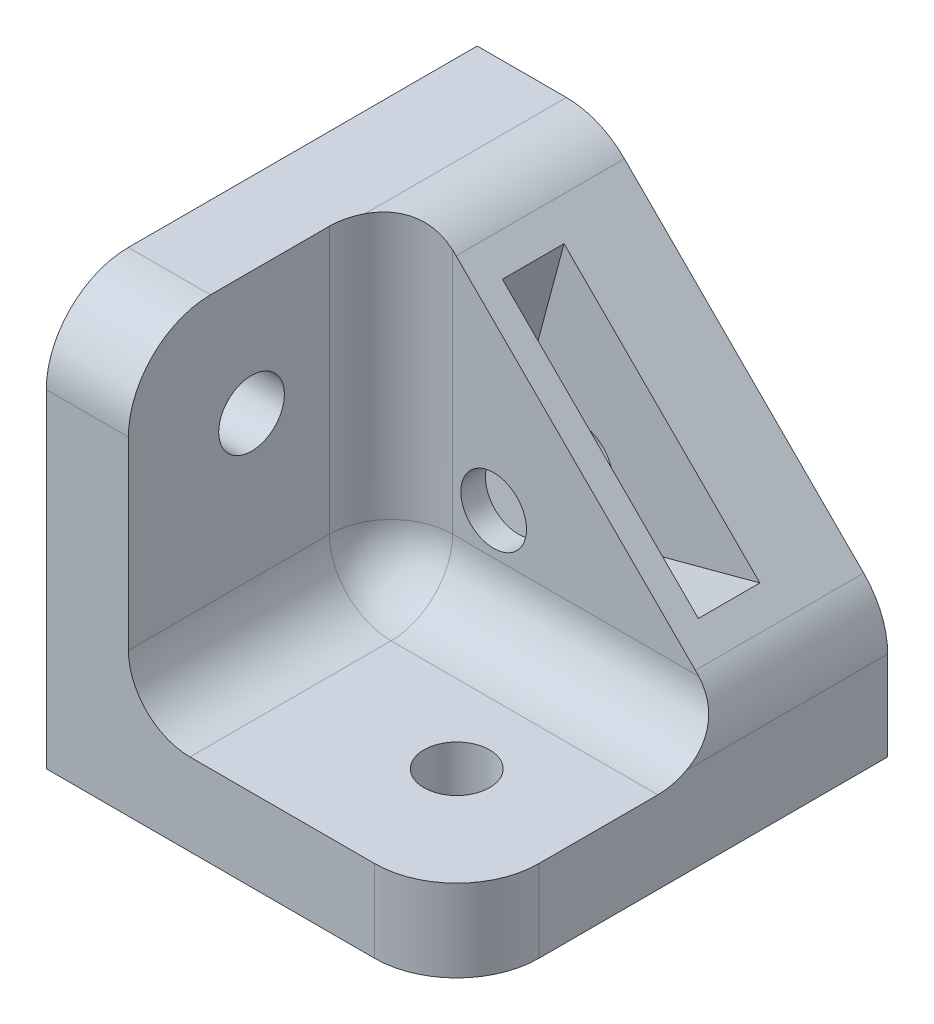
from build123d import *

# Parameters (mm, degrees)
BASE_DEPTH                           = 8.2
SIDES_DEPTH                          = 21
F_3_2_3_2_MOUNTING_HOLES_D           = 3.2
F_3_2_3_2_MOUNTING_HOLES_ON_FACE_2_D = 3.2
F_3_2_3_2_MOUNTING_HOLES_ON_FACE_3_D = 3.2
INSIDEFILLET_R                       = 3
OUTSIDEFILLET_R                      = 4
NUTSLOT_START                        = -4
NUTSLOT_DEPTH                        = 3


with BuildPart() as part:
    # Sketch4 → Base (new body)
    with BuildSketch(Plane.XY):
        Polygon((0, 20), (0, 0), (20, 0), (20, 6), (6, 20), align=None)
    extrude(amount=BASE_DEPTH)

    # Sketch4_4 → Sides (add)
    with BuildSketch(Plane.XY):
        Polygon((0, 20), (0, 0), (20, 0), (20, 4), (4, 4), (4, 20), align=None)
    extrude(amount=SIDES_DEPTH)

    # Ø3.2 (3.2) Mounting Holes (through all)
    with Locations(Plane(origin=(14, 0, 15), x_dir=(0, 0, -1), z_dir=(0, -1, 0))):
        with Locations((0, 0)):
            Hole(F_3_2_3_2_MOUNTING_HOLES_D / 2)

    # Ø3.2 (3.2) Mounting Holes on face 2 (through all)
    with Locations(Plane(origin=(0, 14, 15), x_dir=(0, 0, -1), z_dir=(-1, 0, 0))):
        with Locations((0, 0)):
            Hole(F_3_2_3_2_MOUNTING_HOLES_ON_FACE_2_D / 2)

    # Ø3.2 (3.2) Mounting Holes on face 3 (through all)
    with Locations(Plane(origin=(9, 9, 0), x_dir=(-1, 0, 0), z_dir=(0, 0, -1))):
        with Locations((0, 0)):
            Hole(F_3_2_3_2_MOUNTING_HOLES_ON_FACE_3_D / 2)

    # InsideFillet
    insidefillet_edges = [part.edges().sort_by_distance(p)[0] for p in [
        (12, 4, 8.2),
        (4, 4, 14.6),
        (4, 12, 8.2),
    ]]
    fillet(insidefillet_edges, radius=INSIDEFILLET_R)

    # OutsideFillet
    outsidefillet_edges = [part.edges().sort_by_distance(p)[0] for p in [
        (6, 20, 4.185786438),
        (20, 6, 4.185786438),
        (20, 2, 21),
        (2, 20, 21),
    ]]
    fillet(outsidefillet_edges, radius=OUTSIDEFILLET_R)

    # Sketch7 → NutSlot (cut)
    with BuildSketch(Plane(origin=(0, 0, 0), x_dir=(-1, 0, 0), z_dir=(0, 0, -1)).offset(NUTSLOT_START)):
        Polygon((-8.228417185, 17.771582815), (-5.641242789, 8.116116524), (-8.116116524, 5.641242789), (-17.771582815, 8.228417185), align=None)
    extrude(amount=-NUTSLOT_DEPTH, mode=Mode.SUBTRACT)


solid = part.part
